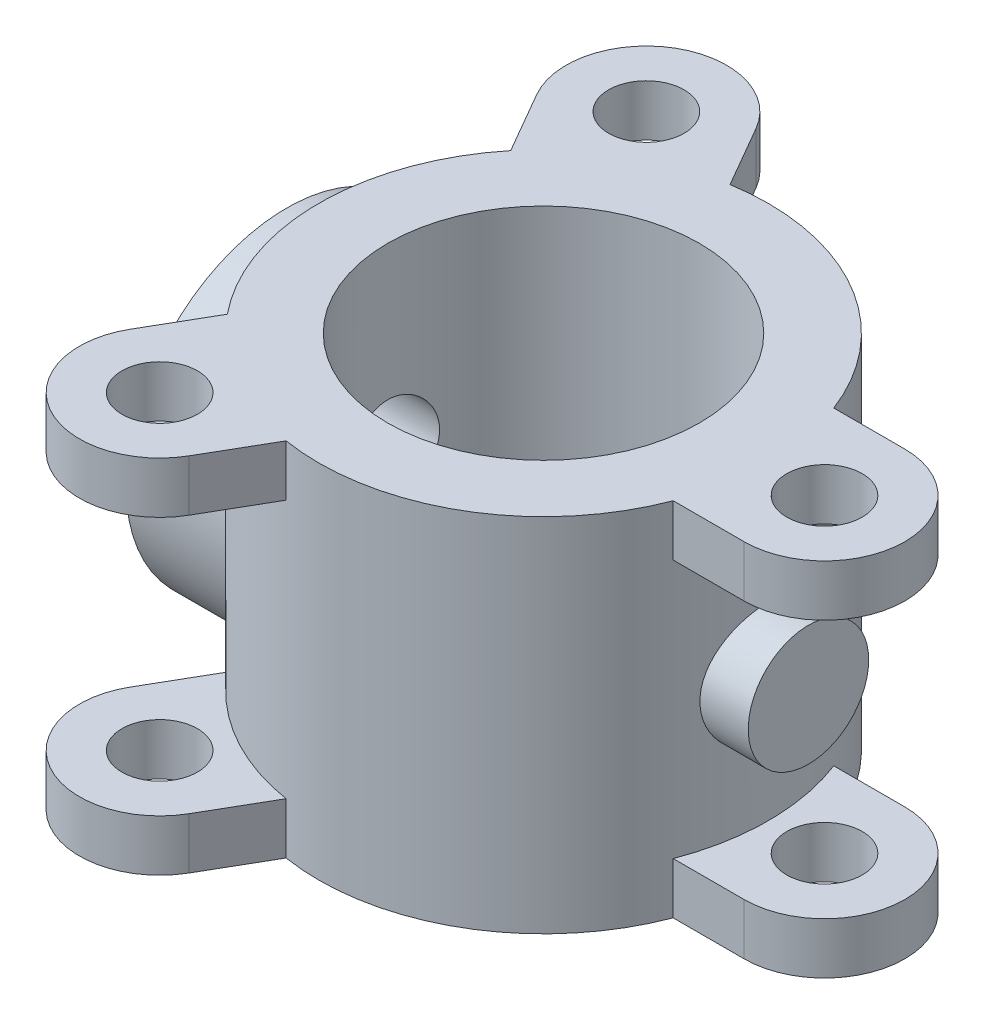
from build123d import *

# Parameters (mm, degrees)
SKETCH1_R                = 140
SKETCH1_R_2              = 97
BOSS_EXTRUDE1_DEPTH      = 112.5
SKETCH2_R                = 23.5
BOSS_EXTRUDE2_DEPTH      = 32
CIRPATTERN1_COUNT        = 3
MIRROR1_COPY_1_SKETCH_R  = 23.5
MIRROR1_COPY_1_DEPTH     = 32
MIRROR1_COPY_2_SKETCH_R  = 23.5
MIRROR1_COPY_2_DEPTH     = 32
SKETCH3_R                = 28.1
CUT_EXTRUDE1_DEPTH       = 310
BOSS_EXTRUDE3_REACH      = 450.894
BOSS_EXTRUDE3_END_RADIUS = 140
SKETCH4_R                = 100
SKETCH5_R                = 50
CUT_EXTRUDE2_DEPTH       = 25
SKETCH6_R                = 10.15
CUT_EXTRUDE3_DEPTH       = 13
BOSS_EXTRUDE4_REACH      = 400.629
BOSS_EXTRUDE4_END_RADIUS = 140
SKETCH7_R                = 37.5
SKETCH7_R_2              = 28.1
SKETCH8_R                = 37.5
BOSS_EXTRUDE5_DEPTH      = 10


with BuildPart() as part:
    # Sketch1 → Boss-Extrude1 (new, symmetric)
    with BuildSketch(Plane(origin=(0, 0, 0), x_dir=(1, 0, 0), z_dir=(0, 1, 0))):
        with Locations(Location((0, 0, 0), (0, 0, 270))):
            Circle(SKETCH1_R)
        with Locations(Location((0, 0, 0), (0, 0, 270))):
            Circle(SKETCH1_R_2, mode=Mode.SUBTRACT)
    extrude(amount=BOSS_EXTRUDE1_DEPTH, both=True)

    # Sketch2 → Boss-Extrude2 (add)
    with BuildSketch(Plane(origin=(0, 112.5, 0), x_dir=(1, 0, 0), z_dir=(0, 1, 0))):
        with BuildLine():
            ThreePointArc((175, -50), (225, 0), (175, 50))
            Line((175, 50), (130.766968306, 50))
            ThreePointArc((130.766968306, 50), (137.672392953, 25.42267135), (140, 0))
            ThreePointArc((140, 0), (137.672392953, -25.42267135), (130.766968306, -50))
            Line((130.766968306, -50), (175, -50))
        make_face()
        with Locations(Location((175, 0, 0), (0, 0, 270))):
            Circle(SKETCH2_R, mode=Mode.SUBTRACT)
    boss_extrude2 = extrude(amount=-BOSS_EXTRUDE2_DEPTH)

    # CirPattern1: Boss-Extrude2 ×3 about axis
    cirpattern1_axis = Axis((0, 0, 0), (0, 1, 0))
    for i in range(1, CIRPATTERN1_COUNT):
        add(boss_extrude2.rotate(cirpattern1_axis, i * 360 / CIRPATTERN1_COUNT))

    # Mirror1: Boss-Extrude2 across plane
    add(boss_extrude2.mirror(Plane.ZX))

    # Mirror1 copy 1 sketch → Mirror1 copy 1 (add)
    with BuildSketch(Plane(origin=(0, -112.5, 0), x_dir=(-0.4999999999999998, 0, -0.8660254037844387), z_dir=(0, -1, 0))):
        with BuildLine():
            ThreePointArc((175, 50), (225, 0), (175, -50))
            Line((175, -50), (130.766968306, -50))
            ThreePointArc((130.766968306, -50), (137.672392953, -25.42267135), (140, 0))
            ThreePointArc((140, 0), (137.672392953, 25.42267135), (130.766968306, 50))
            Line((130.766968306, 50), (175, 50))
        make_face()
        with Locations((175, 0)):
            Circle(MIRROR1_COPY_1_SKETCH_R, mode=Mode.SUBTRACT)
    extrude(amount=-MIRROR1_COPY_1_DEPTH)

    # Mirror1 copy 2 sketch → Mirror1 copy 2 (add)
    with BuildSketch(Plane(origin=(0, -112.5, 0), x_dir=(-0.5000000000000004, 0, 0.8660254037844384), z_dir=(0, -1, 0))):
        with BuildLine():
            ThreePointArc((175, 50), (225, 0), (175, -50))
            Line((175, -50), (130.766968306, -50))
            ThreePointArc((130.766968306, -50), (137.672392953, -25.42267135), (140, 0))
            ThreePointArc((140, 0), (137.672392953, 25.42267135), (130.766968306, 50))
            Line((130.766968306, 50), (175, 50))
        make_face()
        with Locations((175, 0)):
            Circle(MIRROR1_COPY_2_SKETCH_R, mode=Mode.SUBTRACT)
    extrude(amount=-MIRROR1_COPY_2_DEPTH)

    # Sketch3 → Cut-Extrude1 (cut)
    with BuildSketch(Plane(origin=(-160, 0, 0), x_dir=(0, 0, -1), z_dir=(1, 0, 0))):
        with Locations(Location((0, 0, 0), (0, 0, 180))):
            Circle(SKETCH3_R)
    extrude(amount=CUT_EXTRUDE1_DEPTH, mode=Mode.SUBTRACT)

    # Boss-Extrude3: up to this cylinder (the profile starts outside it)
    boss_extrude3_end = Plane(origin=(0, 0, 0), z_dir=(0, -1, 0)) * Cylinder(BOSS_EXTRUDE3_END_RADIUS, 1182.788, mode=Mode.PRIVATE)
    # Sketch4 → Boss-Extrude3 (add, up to the surface)
    with BuildSketch(Plane(origin=(-160, 0, 0), x_dir=(0, 0, -1), z_dir=(1, 0, 0)), mode=Mode.PRIVATE) as boss_extrude3_sk1:
        with Locations(Location((0, 0, 0), (0, 0, 180))):
            Circle(SKETCH4_R)
    boss_extrude3_tool1 = extrude(boss_extrude3_sk1.sketch, amount=BOSS_EXTRUDE3_REACH, mode=Mode.PRIVATE) - boss_extrude3_end
    add(boss_extrude3_tool1.solids().sort_by_distance((-160, 0, 0))[0])

    # Sketch5 → Cut-Extrude2 (cut)
    with BuildSketch(Plane.ZY.offset(160)):
        Circle(SKETCH5_R)
    extrude(amount=-CUT_EXTRUDE2_DEPTH, mode=Mode.SUBTRACT)

    # Sketch6 → Cut-Extrude3 (cut)
    with BuildSketch(Plane.ZY.offset(160)):
        with Locations((0, 75)):
            Circle(SKETCH6_R)
        with Locations((64.951905284, -37.5)):
            Circle(SKETCH6_R)
        with Locations((-64.951905284, -37.5)):
            Circle(SKETCH6_R)
    extrude(amount=-CUT_EXTRUDE3_DEPTH, mode=Mode.SUBTRACT)

    # Boss-Extrude4: up to this cylinder (the profile starts outside it)
    boss_extrude4_end = Plane(origin=(0, 0, 0), z_dir=(0, -1, 0)) * Cylinder(BOSS_EXTRUDE4_END_RADIUS, 1082.258, mode=Mode.PRIVATE)
    # Sketch7 → Boss-Extrude4 (add, up to the surface)
    with BuildSketch(Plane(origin=(165, 0, 0), x_dir=(0, 0, -1), z_dir=(1, 0, 0)), mode=Mode.PRIVATE) as boss_extrude4_sk1:
        Circle(SKETCH7_R)
        with Locations(Location((0, 0, 0), (0, 0, 180))):
            Circle(SKETCH7_R_2, mode=Mode.SUBTRACT)
    boss_extrude4_tool1 = extrude(boss_extrude4_sk1.sketch, amount=-BOSS_EXTRUDE4_REACH, mode=Mode.PRIVATE) - boss_extrude4_end
    add(boss_extrude4_tool1.solids().sort_by_distance((165, 0, 36.43934))[0])

    # Sketch8 → Boss-Extrude5 (add)
    with BuildSketch(Plane(origin=(165, 0, 0), x_dir=(0, 0, -1), z_dir=(1, 0, 0))):
        Circle(SKETCH8_R)
    extrude(amount=-BOSS_EXTRUDE5_DEPTH)


solid = part.part
